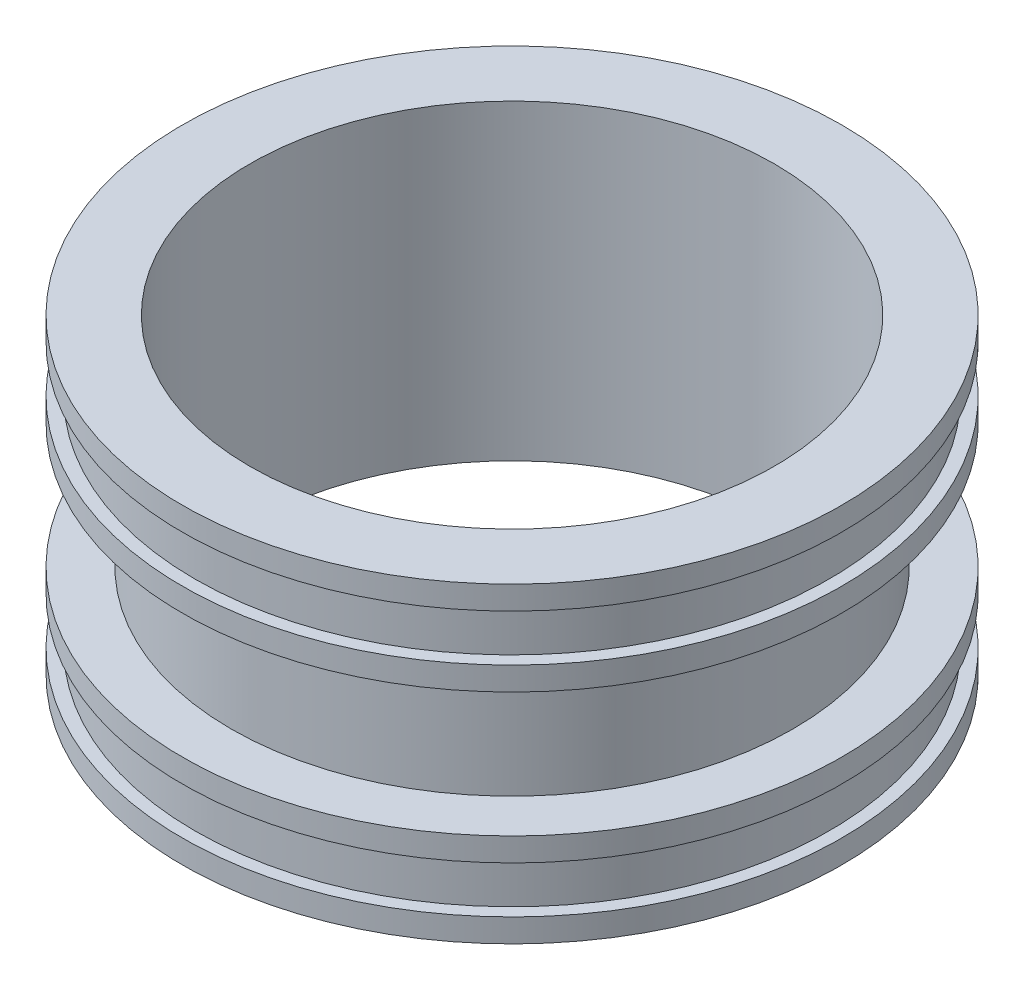
from build123d import *


with BuildPart() as part:
    # Esboço1 → Revolução1 (revolve)
    with BuildSketch(Plane.XY):
        Polygon((84.14, 100), (105.78, 100), (105.78, 92.5), (101.78, 92.5), (101.78, 77.5), (105.78, 77.5), (105.78, 70), (90.14, 70), (90.14, 30), (105.78, 30), (105.78, 22.5), (101.78, 22.5), (101.78, 7.5), (105.78, 7.5), (105.78, 0), (84.14, 0), align=None)
    revolve(axis=Axis((0, 0, 0), (0, 1, 0)))


solid = part.part
